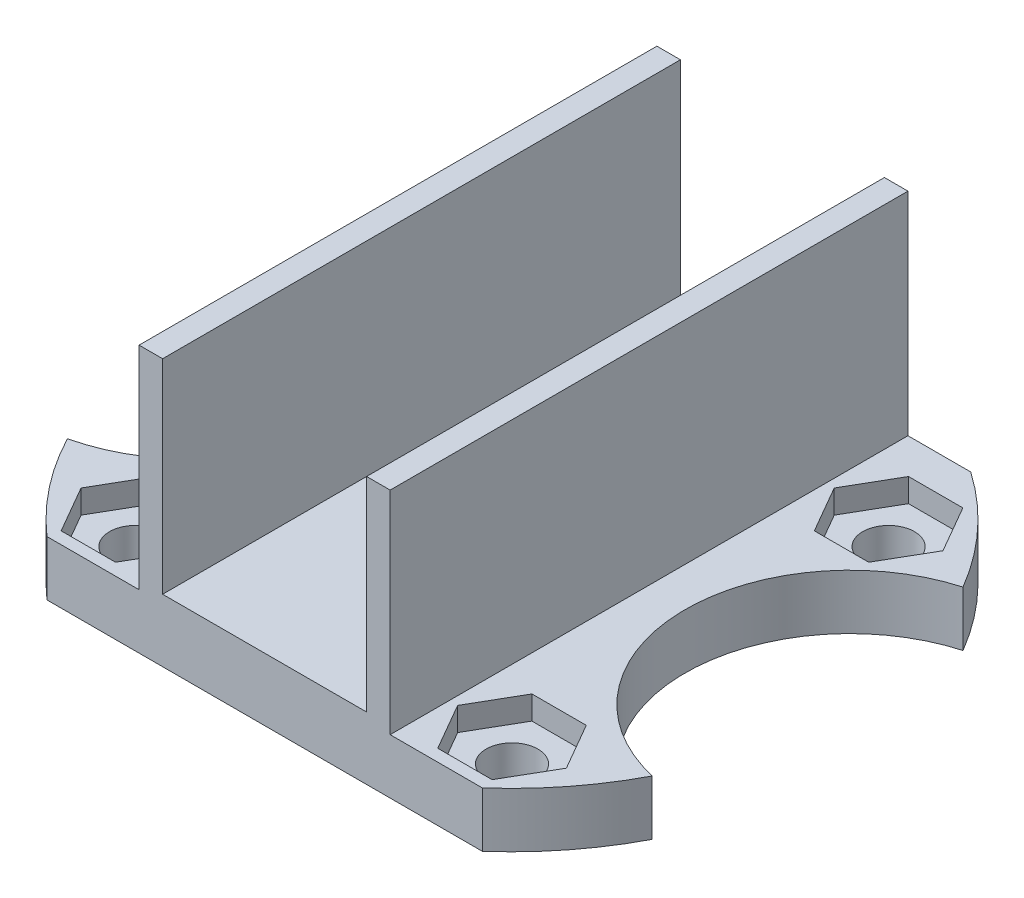
from build123d import *

# Parameters (mm, degrees)
SKETCH1_R               = 21
SKETCH1_R_2             = 1.65
BOSS_EXTRUDE2_DEPTH     = 3.5
CUT_EXTRUDE1_DEPTH      = 44.967799759
CUT_EXTRUDE1_DEPTH_BACK = 44.967799759
BOSS_EXTRUDE3_DEPTH     = 33
CUT_EXTRUDE2_START      = -3.5
CUT_EXTRUDE2_DEPTH      = 1.5
SKETCH7_R               = 10.5
SKETCH7_W               = 41.986856553
SKETCH7_H               = 9.070253879
CUT_EXTRUDE3_DEPTH      = 45.774448723


with BuildPart() as part:
    # Sketch1 → Boss-Extrude2 (new body)
    with BuildSketch(Plane(origin=(0, 0, 0), x_dir=(1, 0, 0), z_dir=(0, 1, 0))):
        with Locations((-11.755661444, 8.120165848)):
            Circle(SKETCH1_R)
        with Locations((-23.755661444, 20.120165848)):
            Circle(SKETCH1_R_2, mode=Mode.SUBTRACT)
        with Locations((0.244338556, 20.120165848)):
            Circle(SKETCH1_R_2, mode=Mode.SUBTRACT)
        with Locations((-23.755661444, -3.879834152)):
            Circle(SKETCH1_R_2, mode=Mode.SUBTRACT)
        with Locations((0.244338556, -3.879834152)):
            Circle(SKETCH1_R_2, mode=Mode.SUBTRACT)
    extrude(amount=BOSS_EXTRUDE2_DEPTH)

    # Sketch3 → Cut-Extrude1 (cut, two sides: drawn at the far end of the back side and taken through both)
    with BuildSketch(Plane(origin=(0, 3.5, 0), x_dir=(1, 0, 0), z_dir=(0, 1, 0)).offset(-CUT_EXTRUDE1_DEPTH_BACK)):
        Polygon((-134.766846833, 25.353853788), (-23.755661444, 25.353853788), (0.244338556, 25.353853788), (111.255523946, 25.353853788), (111.255523946, 247.376224567), (-134.766846833, 247.376224567), align=None)
    extrude(amount=CUT_EXTRUDE1_DEPTH + CUT_EXTRUDE1_DEPTH_BACK, mode=Mode.SUBTRACT)

    # Sketch4 → Boss-Extrude3 (add)
    with BuildSketch(Plane(origin=(0, 0, -25.353853788), x_dir=(-1, 0, 0), z_dir=(0, 0, -1))):
        Polygon((3.755661444, 13.225065807), (3.755661444, 3.5), (19.755661444, 3.5), (19.755661444, 13.225065807), (19.755661444, 17), (18.255661444, 17), (18.255661444, 4), (5.255661444, 4), (5.255661444, 17), (3.755661444, 17), align=None)
    extrude(amount=-BOSS_EXTRUDE3_DEPTH)

    # Sketch6 → Cut-Extrude2 (cut)
    with BuildSketch(Plane.XZ.offset(CUT_EXTRUDE2_START)):
        Polygon((-22.023610636, -17.120165848), (-25.487712251, -17.120165848), (-27.219763059, -20.120165848), (-25.487712251, -23.120165848), (-22.023610636, -23.120165848), (-20.291559828, -20.120165848), align=None)
        Polygon((-22.023610636, 0.879834152), (-20.291559828, 3.879834152), (-22.023610636, 6.879834152), (-25.487712251, 6.879834152), (-27.219763059, 3.879834152), (-25.487712251, 0.879834152), align=None)
        Polygon((1.976389364, 0.879834152), (3.708440172, 3.879834152), (1.976389364, 6.879834152), (-1.487712251, 6.879834152), (-3.219763059, 3.879834152), (-1.487712251, 0.879834152), align=None)
        Polygon((1.976389364, -17.120165848), (-1.487712251, -17.120165848), (-3.219763059, -20.120165848), (-1.487712251, -23.120165848), (1.976389364, -23.120165848), (3.708440172, -20.120165848), align=None)
    extrude(amount=CUT_EXTRUDE2_DEPTH, mode=Mode.SUBTRACT)

    # Sketch7 → Cut-Extrude3 (cut, through all)
    with BuildSketch(Plane.XZ):
        with Locations((-32.749417947, -8.63220869)):
            Circle(SKETCH7_R)
        with Locations((9.237438606, -8.658450465)):
            Circle(SKETCH7_R)
        with Locations((-11.755989671, 12.181273152)):
            Rectangle(SKETCH7_W, SKETCH7_H)
    extrude(amount=-CUT_EXTRUDE3_DEPTH, mode=Mode.SUBTRACT)


solid = part.part
